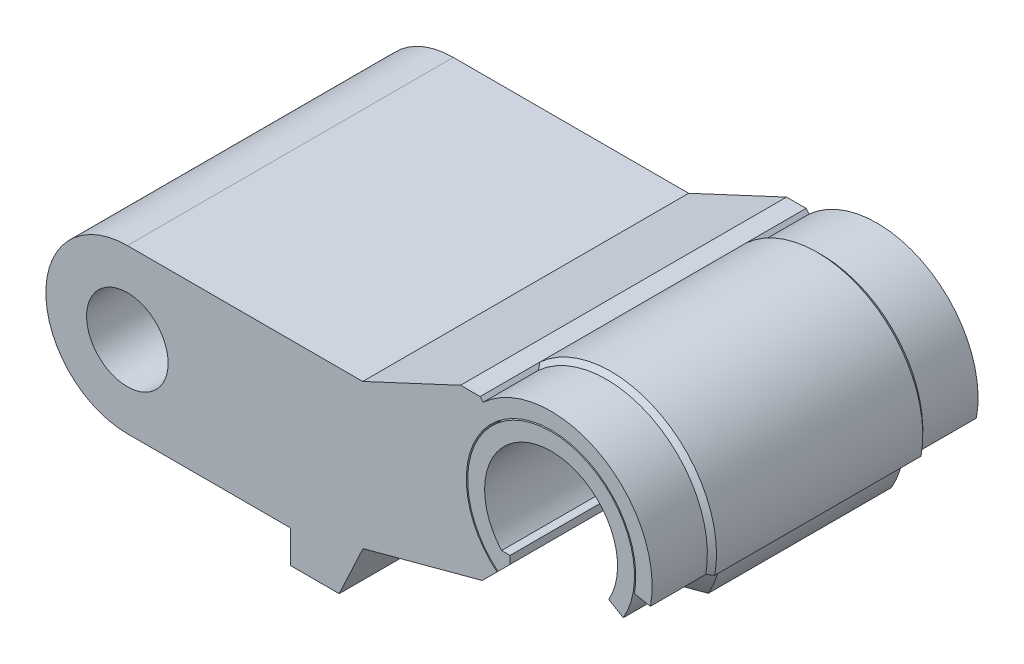
from build123d import *

# Parameters (mm, degrees)
BOSS_EXTRUDE1_DEPTH     = 25
CUT_EXTRUDE1_DEPTH      = 2.6
CUT_EXTRUDE2_DEPTH      = 26
CUT_EXTRUDE2_DEPTH_BACK = 26
BOSS_EXTRUDE2_DEPTH     = 25
BOSS_EXTRUDE3_START     = -9.175736
BOSS_EXTRUDE3_DEPTH     = 9.175736
SKETCH15_R              = 6.25
CUT_EXTRUDE3_DEPTH      = 26
CUT_EXTRUDE3_DEPTH_BACK = 26
CUT_EXTRUDE4_DEPTH      = 26
CUT_EXTRUDE4_DEPTH_BACK = 26


with BuildPart() as part:
    # Sketch3 → Boss-Extrude1 (new body, symmetric)
    with BuildSketch(Plane.XY):
        with BuildLine():
            Line((6.3, -8.014378278), (9.856597623, -11.570975901))
            ThreePointArc((9.856597623, -11.570975901), (0, 15.2), (-9.856597623, -11.570975901))
            Line((-9.856597623, -11.570975901), (-6.3, -8.014378278))
            Line((-6.3, -8.014378278), (-6.3, -6.814378278))
            Line((-6.3, -6.814378278), (-7.589746286, -6.814378278))
            ThreePointArc((-7.589746286, -6.814378278), (0, 10.2), (7.589746286, -6.814378278))
            Line((7.589746286, -6.814378278), (6.3, -6.814378278))
            Line((6.3, -6.814378278), (6.3, -8.014378278))
        make_face()
    extrude(amount=BOSS_EXTRUDE1_DEPTH, both=True)

    # Sketch4 → Cut-Extrude1 (cut, symmetric)
    with BuildSketch(Plane(origin=(0, 0, 0), x_dir=(0, 0, -1), z_dir=(1, 0, 0))):
        Polygon((-3.082842712, 15.2), (-9.482842712, 8.8), (9.482842712, 8.8), (3.082842712, 15.2), align=None)
    extrude(amount=CUT_EXTRUDE1_DEPTH, both=True, mode=Mode.SUBTRACT)

    # Sketch5 → Cut-Revolve1 (revolve, cut)
    with BuildSketch(Plane(origin=(0, 0, 0), x_dir=(0, 0, -1), z_dir=(1, 0, 0))):
        Polygon((25, 15.2), (25, 12.8), (16.441421356, 12.8), (14.041421356, 15.2), align=None)
    cut_revolve1 = revolve(axis=Axis((0, 0, 27.223610458), (0, 0, -1)), mode=Mode.SUBTRACT)

    # Mirror1: Cut-Revolve1 across plane
    add(cut_revolve1.mirror(Plane.XY), mode=Mode.SUBTRACT)

    # Sketch16 → Cut-Extrude4 (cut, two sides)
    with BuildSketch(Plane.XY) as cut_extrude4_sk:
        with BuildLine():
            Line((0, 0), (13.163586138, -7.6))
            ThreePointArc((13.163586138, -7.6), (7.6, -13.163586138), (0, -15.2))
            Line((0, -15.2), (0, 0))
        make_face()
    extrude(amount=CUT_EXTRUDE4_DEPTH, mode=Mode.SUBTRACT)
    extrude(cut_extrude4_sk.sketch, amount=-CUT_EXTRUDE4_DEPTH_BACK, mode=Mode.SUBTRACT)


with BuildPart() as body_2:
    # Sketch7 → Revolve1 (revolve)
    with BuildSketch(Plane(origin=(0, 0, 0), x_dir=(0, 0, -1), z_dir=(1, 0, 0))):
        Polygon((25, 13), (16.524264069, 13), (14.124264069, 15.4), (3.082842712, 15.4), (-3.082842712, 15.4), (-14.124264069, 15.4), (-16.524264069, 13), (-25, 13), (-25, 15.5), (-16.524264069, 15.5), (-15.824264069, 16.2), (15.824264069, 16.2), (16.524264069, 15.5), (25, 15.5), align=None)
    revolve(axis=Axis((0, 0, 29.952528939), (0, 0, -1)))

    # Sketch10 → Cut-Extrude2 (cut, two sides)
    with BuildSketch(Plane.XY) as cut_extrude2_sk:
        with BuildLine():
            Line((-6.3, -8.014378278), (-9.856597623, -11.570975901))
            Line((-9.856597623, -11.570975901), (-28.285621722, -30))
            Line((-28.285621722, -30), (0, -30))
            ThreePointArc((0, -30), (19.198137256, -23.052798657), (29.504719516, -5.428768394))
            Line((29.504719516, -5.428768394), (0, 0))
            Line((0, 0), (-6.3, -8.014378278))
        make_face()
    extrude(amount=CUT_EXTRUDE2_DEPTH, mode=Mode.SUBTRACT)
    extrude(cut_extrude2_sk.sketch, amount=-CUT_EXTRUDE2_DEPTH_BACK, mode=Mode.SUBTRACT)

    # Sketch12 → Boss-Extrude2 (add, symmetric)
    with BuildSketch(Plane.XY):
        with BuildLine():
            Line((-40, -20), (-40, -25))
            Line((-40, -25), (-32.5, -25))
            Line((-32.5, -25), (-28.853667702, -17.180415152))
            Line((-28.853667702, -17.180415152), (-10.565823895, -12.280202173))
            ThreePointArc((-10.565823895, -12.280202173), (-16.198617819, -0.211614628), (-10.883014288, 12))
            Line((-10.883014288, 12), (-13.883014288, 12))
            Line((-13.883014288, 12), (-28.894562732, 5))
            Line((-28.894562732, 5), (-65, 5))
            ThreePointArc((-65, 5), (-77.5, -7.5), (-65, -20))
            Line((-65, -20), (-40, -20))
        make_face()
    extrude(amount=BOSS_EXTRUDE2_DEPTH, both=True)

    # Sketch13 → Boss-Extrude3 (add)
    with BuildSketch(Plane(origin=(0, 0, -25), x_dir=(-1, 0, 0), z_dir=(0, 0, -1)).offset(BOSS_EXTRUDE3_START)):
        with BuildLine():
            Line((10.883014288, 12), (10.412760585, 11.481481481))
            ThreePointArc((10.412760585, 11.481481481), (15.498312164, -0.228735824), (10.069394352, -11.78377263))
            Line((10.069394352, -11.78377263), (10.565823895, -12.280202173))
            ThreePointArc((10.565823895, -12.280202173), (16.198617819, -0.211614628), (10.883014288, 12))
        make_face()
    boss_extrude3 = extrude(amount=BOSS_EXTRUDE3_DEPTH)

    # Mirror2: Boss-Extrude3 across plane
    add(boss_extrude3.mirror(Plane.XY))

    # Sketch15 → Cut-Extrude3 (cut, two sides)
    with BuildSketch(Plane.XY) as cut_extrude3_sk:
        with Locations((-65, -7.5)):
            Circle(SKETCH15_R)
    extrude(amount=CUT_EXTRUDE3_DEPTH, mode=Mode.SUBTRACT)
    extrude(cut_extrude3_sk.sketch, amount=-CUT_EXTRUDE3_DEPTH_BACK, mode=Mode.SUBTRACT)


solid = Compound([part.part, body_2.part])
